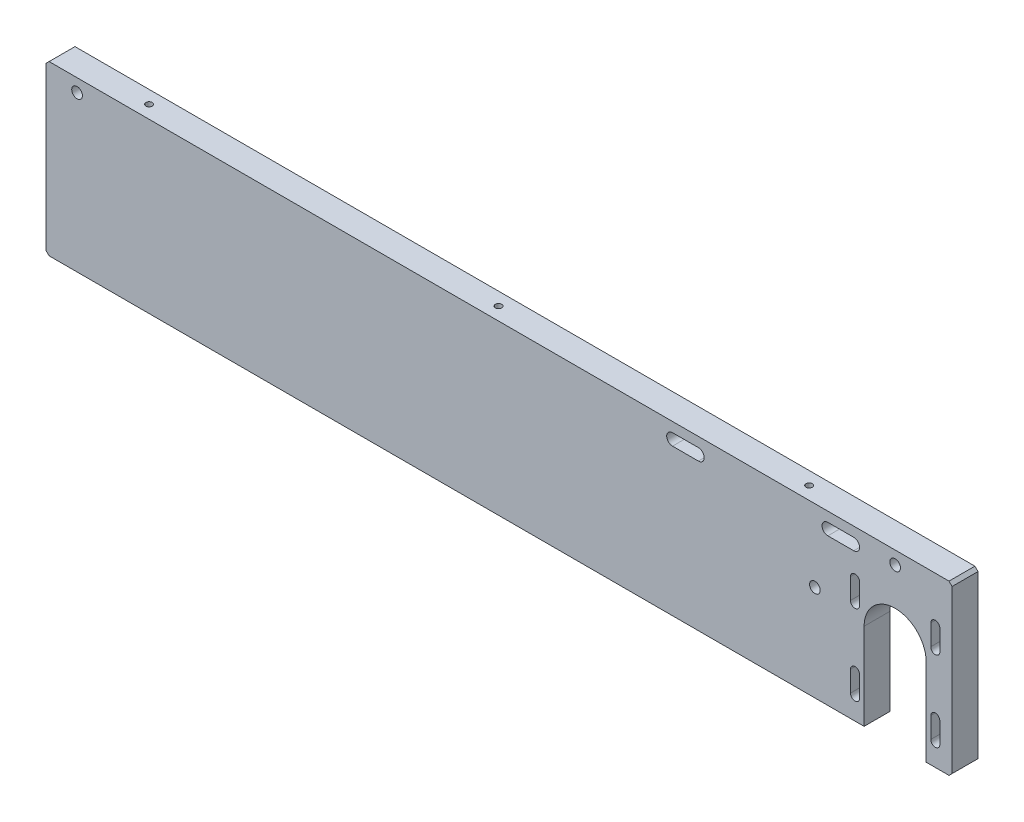
from build123d import *

# Parameters (mm, degrees)
BOSS_EXTRUDE1_DEPTH     = 10
CUT_EXTRUDE1_DEPTH      = 1
CUT_EXTRUDE1_DEPTH_BACK = 11
CUT_EXTRUDE2_DEPTH      = 11
LPATTERN1_COUNT         = 2
LPATTERN1_PITCH         = 31
LPATTERN1_COUNT_DIR2    = 2
LPATTERN1_PITCH_DIR2    = 31
SKETCH5_R               = 2.065
CUT_EXTRUDE3_DEPTH      = 11
SKETCH6_R               = 1.23
CUT_EXTRUDE4_DEPTH      = 8


with BuildPart() as part:
    # Sketch1 → Boss-Extrude1 (new body)
    with BuildSketch(Plane.XY):
        Polygon((348.8, 65), (350, 63.8), (350, 1.2), (348.8, 0), (1.2, 0), (0, 1.2), (0, 63.8), (1.2, 65), align=None)
    extrude(amount=BOSS_EXTRUDE1_DEPTH)

    # Sketch2 → Cut-Extrude1 (cut, two sides)
    with BuildSketch(Plane.XY.offset(10)) as cut_extrude1_sk:
        with BuildLine():
            Line((316, 33.5), (316, 0))
            Line((316, 0), (340, 0))
            Line((340, 0), (340, 33.5))
            ThreePointArc((340, 33.5), (328, 45.5), (316, 33.5))
        make_face()
    extrude(amount=CUT_EXTRUDE1_DEPTH, mode=Mode.SUBTRACT)
    extrude(cut_extrude1_sk.sketch, amount=-CUT_EXTRUDE1_DEPTH_BACK, mode=Mode.SUBTRACT)

    # Sketch3 → Cut-Extrude2 (cut, through all)
    with BuildSketch(Plane.XY.offset(10)):
        with BuildLine():
            Line((345.25, 16.5), (345.25, 8.5))
            ThreePointArc((345.25, 8.5), (343.5, 6.75), (341.75, 8.5))
            Line((341.75, 8.5), (341.75, 16.5))
            ThreePointArc((341.75, 16.5), (343.5, 18.25), (345.25, 16.5))
        make_face()
    cut_extrude2 = extrude(amount=-CUT_EXTRUDE2_DEPTH, mode=Mode.SUBTRACT)

    # LPattern1: Cut-Extrude2 2 × 2
    with Locations(*[(-j * LPATTERN1_PITCH_DIR2, i * LPATTERN1_PITCH, 0) for i in range(LPATTERN1_COUNT) for j in range(LPATTERN1_COUNT_DIR2) if (i, j) != (0, 0)]):
        add(cut_extrude2, mode=Mode.SUBTRACT)

    # Sketch5 → Cut-Extrude3 (cut, through all)
    with BuildSketch(Plane.XY.offset(10)):
        with Locations((328, 60)):
            Circle(SKETCH5_R)
        with Locations((12, 60)):
            Circle(SKETCH5_R)
        with Locations((297, 37)):
            Circle(SKETCH5_R)
        with BuildLine():
            Line((302, 61.25), (312, 61.25))
            ThreePointArc((312, 61.25), (314.25, 59), (312, 56.75))
            Line((312, 56.75), (302, 56.75))
            ThreePointArc((302, 56.75), (299.75, 59), (302, 61.25))
        make_face()
        with BuildLine():
            Line((242, 61.25), (252, 61.25))
            ThreePointArc((252, 61.25), (254.25, 59), (252, 56.75))
            Line((252, 56.75), (242, 56.75))
            ThreePointArc((242, 56.75), (239.75, 59), (242, 61.25))
        make_face()
    extrude(amount=-CUT_EXTRUDE3_DEPTH, mode=Mode.SUBTRACT)

    # Sketch6 → Cut-Extrude4 (cut)
    with BuildSketch(Plane(origin=(0, 65, 0), x_dir=(1, 0, 0), z_dir=(0, 1, 0))):
        with Locations((289.8, -5)):
            Circle(SKETCH6_R)
        with Locations((169.8, -5)):
            Circle(SKETCH6_R)
        with Locations((34.8, -5)):
            Circle(SKETCH6_R)
    extrude(amount=-CUT_EXTRUDE4_DEPTH, mode=Mode.SUBTRACT)


solid = part.part
